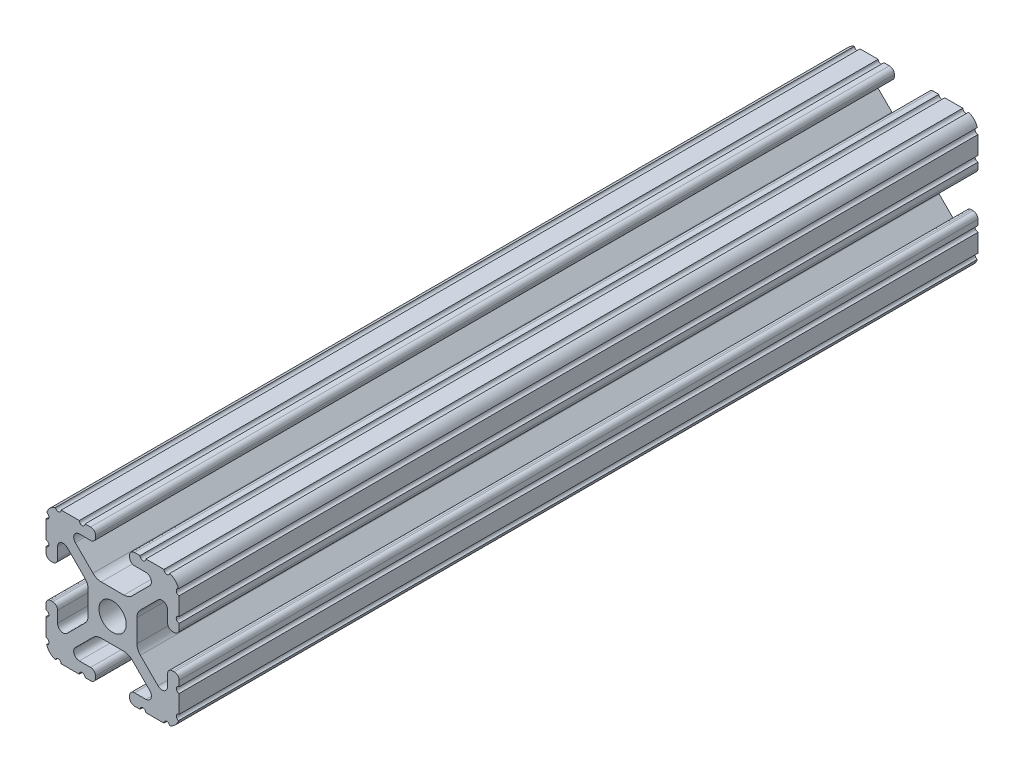
from build123d import *

# Parameters (mm, degrees)
BOSS_EXTRUDE1_DEPTH     = 76.2
SKETCH5_R               = 0.55245
CUT_EXTRUDE1_DEPTH      = 77.2
CUT_EXTRUDE1_DEPTH_BACK = 77.2


with BuildPart() as part:
    # Sketch4 → Boss-Extrude1 (new body, symmetric)
    with BuildSketch(Plane.XY):
        with BuildLine():
            Line((4.190365, -12.7), (10.11729625, -12.7))
            ThreePointArc((10.11729625, -12.7), (11.943543585, -11.943543585), (12.7, -10.11729625))
            Line((12.7, -10.11729625), (12.7, -4.190365))
            ThreePointArc((12.7, -4.190365), (12.42492494, -3.52627506), (11.760835, -3.2512))
            Line((11.760835, -3.2512), (11.429365, -3.2512))
            ThreePointArc((11.429365, -3.2512), (10.76527506, -3.52627506), (10.4902, -4.190365))
            Line((10.4902, -4.190365), (10.4902, -6.348478019))
            ThreePointArc((10.4902, -6.348478019), (9.830707141, -7.335478831), (8.666460301, -7.103895736))
            Line((8.666460301, -7.103895736), (5.299899128, -3.737334563))
            ThreePointArc((5.299899128, -3.737334563), (4.817571085, -3.015479634), (4.6482, -2.16399369))
            Line((4.6482, -2.16399369), (4.6482, 0))
            Line((4.6482, 0), (2.6035, 0))
            ThreePointArc((2.6035, 0), (1.840952505, -1.840952505), (0, -2.6035))
            Line((0, -2.6035), (0, -4.6482))
            Line((0, -4.6482), (2.16399369, -4.6482))
            ThreePointArc((2.16399369, -4.6482), (3.015479634, -4.817571085), (3.737334563, -5.299899128))
            Line((3.737334563, -5.299899128), (7.103895736, -8.666460301))
            ThreePointArc((7.103895736, -8.666460301), (7.335478831, -9.830707141), (6.348478019, -10.4902))
            Line((6.348478019, -10.4902), (4.190365, -10.4902))
            ThreePointArc((4.190365, -10.4902), (3.52627506, -10.76527506), (3.2512, -11.429365))
            Line((3.2512, -11.429365), (3.2512, -11.760835))
            ThreePointArc((3.2512, -11.760835), (3.52627506, -12.42492494), (4.190365, -12.7))
        make_face()
    extrude(amount=BOSS_EXTRUDE1_DEPTH, both=True)

    # Sketch5 → Cut-Extrude1 (cut, two sides)
    with BuildSketch(Plane.XY) as cut_extrude1_sk:
        with Locations((10.356153152, -12.7)):
            Circle(SKETCH5_R)
        with Locations((5.796028019, -12.7)):
            Circle(SKETCH5_R)
        with Locations((12.7, -10.356153152)):
            Circle(SKETCH5_R)
        with Locations((12.7, -5.796028019)):
            Circle(SKETCH5_R)
    extrude(amount=CUT_EXTRUDE1_DEPTH, mode=Mode.SUBTRACT)
    extrude(cut_extrude1_sk.sketch, amount=-CUT_EXTRUDE1_DEPTH_BACK, mode=Mode.SUBTRACT)

    # Mirror1: part across plane


with BuildPart() as part_1:
    add(part.part)
    add(part.part.mirror(Plane(origin=(0, 0, 0), x_dir=(0, 0, 1), z_dir=(1, 0, 0))))

    # Mirror2: part across plane


with BuildPart() as part_2:
    add(part_1.part)
    add(part_1.part.mirror(Plane.ZX))


solid = part_2.part
